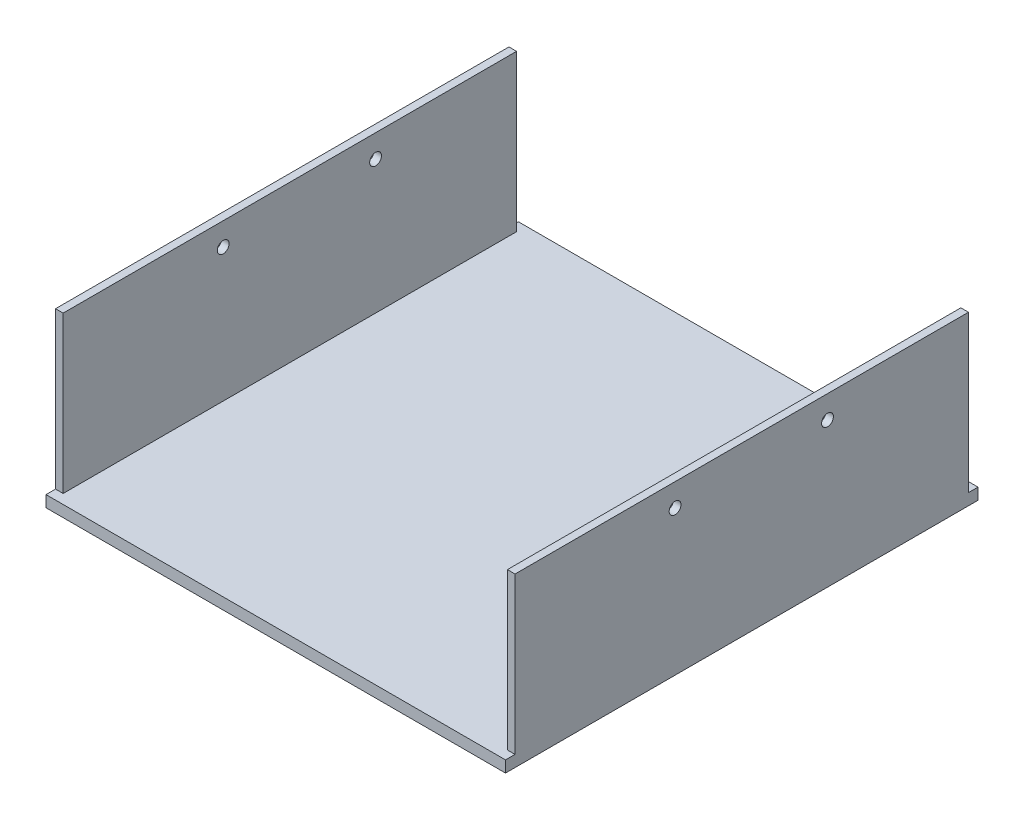
from build123d import *

# Parameters (mm, degrees)
SKETCH3_W           = 120.6
SKETCH3_H           = 124
BOSS_EXTRUDE3_DEPTH = 44
SKETCH9_W           = 116.6
SKETCH9_H           = 124
CUT_EXTRUDE2_DEPTH  = 42
SKETCH10_W          = 120.6
SKETCH10_H          = 2.5
CUT_EXTRUDE3_DEPTH  = 42
SKETCH11_W          = 120.6
SKETCH11_H          = 2.5
CUT_EXTRUDE4_DEPTH  = 42
SKETCH12_R          = 1.55
CUT_EXTRUDE5_DEPTH  = 124.6


with BuildPart() as part:
    # Sketch3 → Boss-Extrude3 (new body)
    with BuildSketch(Plane(origin=(0, 0, 0), x_dir=(1, 0, 0), z_dir=(0, 1, 0))):
        Rectangle(SKETCH3_W, SKETCH3_H)
    extrude(amount=BOSS_EXTRUDE3_DEPTH)

    # Sketch9 → Cut-Extrude2 (cut, through all)
    with BuildSketch(Plane(origin=(0, 3, 0), x_dir=(1, 0, 0), z_dir=(0, 1, 0))):
        Rectangle(SKETCH9_W, SKETCH9_H)
    extrude(amount=CUT_EXTRUDE2_DEPTH, mode=Mode.SUBTRACT)

    # Sketch10 → Cut-Extrude3 (cut, through all)
    with BuildSketch(Plane(origin=(0, 3, 0), x_dir=(1, 0, 0), z_dir=(0, 1, 0))):
        with Locations((0, 60.75)):
            Rectangle(SKETCH10_W, SKETCH10_H)
    extrude(amount=CUT_EXTRUDE3_DEPTH, mode=Mode.SUBTRACT)

    # Sketch11 → Cut-Extrude4 (cut, through all)
    with BuildSketch(Plane(origin=(0, 3, 0), x_dir=(1, 0, 0), z_dir=(0, 1, 0))):
        with Locations((0, -60.75)):
            Rectangle(SKETCH11_W, SKETCH11_H)
    extrude(amount=CUT_EXTRUDE4_DEPTH, mode=Mode.SUBTRACT)

    # Sketch12 → Cut-Extrude5 (cut, through all)
    with BuildSketch(Plane.ZY.offset(63.3)):
        with Locations((-22.5, 38)):
            Circle(SKETCH12_R)
        with Locations((17.5, 38)):
            Circle(SKETCH12_R)
    extrude(amount=-CUT_EXTRUDE5_DEPTH, mode=Mode.SUBTRACT)


solid = part.part
